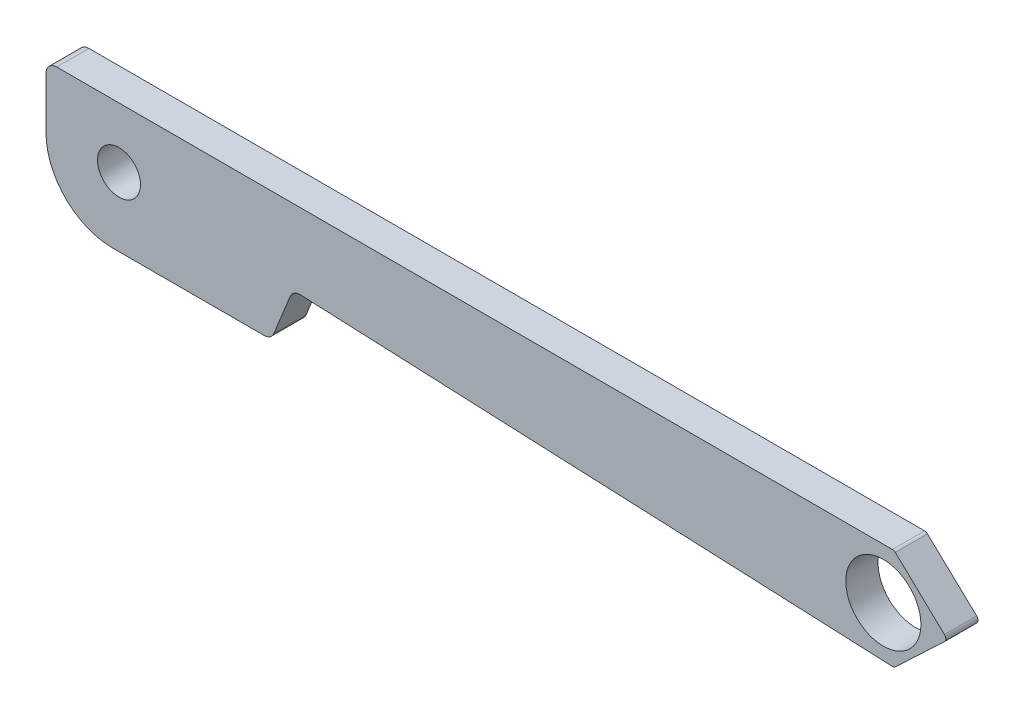
from build123d import *

# Parameters (mm, degrees)
SKETCH1_R           = 1.75
BOSS_EXTRUDE1_DEPTH = 1.5
FILLET1_R           = 0.5
FILLET2_R           = 0.2
SKETCH5_R           = 1
CUT_EXTRUDE3_DEPTH  = 2.5
FILLET3_R           = 3.1


with BuildPart() as part:
    # Sketch1 → Boss-Extrude1 (new body)
    with BuildSketch(Plane.XY):
        Polygon((0, 0), (0, 6), (39.5, 6), (42, 3.638746799), (39.5, 1.277493599), (11.5, 2.5), (10.489934435, 0), align=None)
        with Locations((39, 3.638746799)):
            Circle(SKETCH1_R, mode=Mode.SUBTRACT)
    extrude(amount=BOSS_EXTRUDE1_DEPTH)

    # Fillet1
    fillet1_edges = [part.edges().sort_by_distance(p)[0] for p in [
        (0, 6, 0.75),
        (11.5, 2.5, 0.75),
        (10.489934435, 0, 0.75),
    ]]
    fillet(fillet1_edges, radius=FILLET1_R)

    # Fillet2
    fillet2_edges = [part.edges().sort_by_distance(p)[0] for p in [
        (39.5, 6, 0.75),
        (42, 3.638746799, 0.75),
        (39.5, 1.277493599, 0.75),
    ]]
    fillet(fillet2_edges, radius=FILLET2_R)

    # Sketch5 → Cut-Extrude3 (cut, through all)
    with BuildSketch(Plane.XY.offset(1.5)):
        with Locations((3.4, 3.2)):
            Circle(SKETCH5_R)
    extrude(amount=-CUT_EXTRUDE3_DEPTH, mode=Mode.SUBTRACT)

    # Fillet3
    fillet3_edges = [part.edges().sort_by_distance(p)[0] for p in [
        (0, 0, 0.75),
    ]]
    fillet(fillet3_edges, radius=FILLET3_R)


solid = part.part
